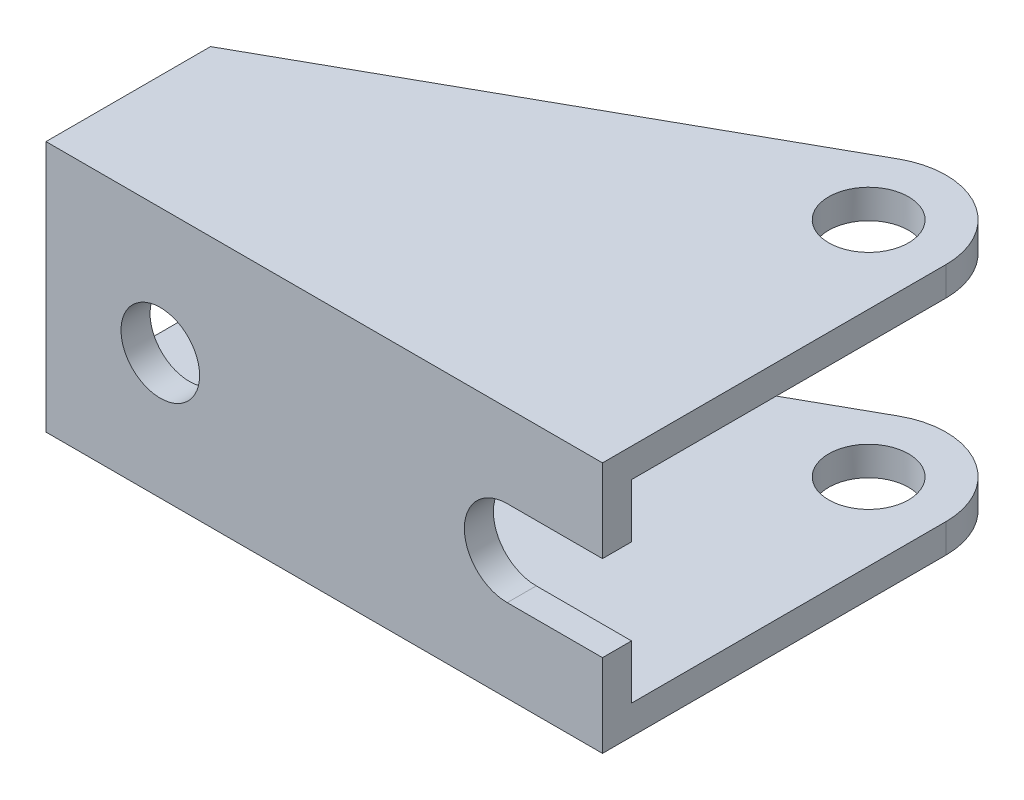
from build123d import *

# Parameters (mm, degrees)
SKETCH1_R           = 8.128
SKETCH1_R_2         = 4.191
BOSS_EXTRUDE1_DEPTH = 26.416
CUT_EXTRUDE1_REACH  = 60.42
SKETCH2_W           = 41.148
SKETCH2_H           = 20.32
CUT_EXTRUDE2_REACH  = 46.196
SKETCH3_R           = 4.125


with BuildPart() as part:
    # Sketch1 → Boss-Extrude1 (new body)
    with BuildSketch(Plane(origin=(0, 0, 0), x_dir=(1, 0, 0), z_dir=(0, 1, 0))):
        with BuildLine():
            Line((-58.42, 0), (0, 0))
            Line((0, 0), (0, 36.068))
            ThreePointArc((0, 36.068), (-12.241042079, 29.057488688), (-12.09332403, 43.163110242))
            Line((-12.09332403, 43.163110242), (-58.42, 17.272))
            Line((-58.42, 17.272), (-58.42, 0))
        make_face()
        with Locations((-8.128, 36.068)):
            Circle(SKETCH1_R)
        with Locations(Location((-8.128, 36.068, 0), (0, 0, 270))):  # turned: the seam where the file's is
            Circle(SKETCH1_R_2, mode=Mode.SUBTRACT)
    extrude(amount=-BOSS_EXTRUDE1_DEPTH)

    # Sketch2 → Cut-Extrude1 (cut, up to next)
    with BuildSketch(Plane(origin=(0, 0, 0), x_dir=(0, 0, -1), z_dir=(1, 0, 0)), mode=Mode.PRIVATE) as cut_extrude1_sk1:
        with Locations((23.622, -13.208)):
            Rectangle(SKETCH2_W, SKETCH2_H)
    cut_extrude1_tool1 = extrude(cut_extrude1_sk1.sketch, amount=-CUT_EXTRUDE1_REACH, mode=Mode.PRIVATE) & part.part
    add(cut_extrude1_tool1.solids().sort_by_distance((0, -13.208, -23.622))[0], mode=Mode.SUBTRACT)

    # Sketch3 → Cut-Extrude2 (cut, up to next)
    with BuildSketch(Plane.XY, mode=Mode.PRIVATE) as cut_extrude2_sk1:
        with Locations((-46.42, -13.208)):
            Circle(SKETCH3_R)
    cut_extrude2_tool1 = extrude(cut_extrude2_sk1.sketch, amount=-CUT_EXTRUDE2_REACH, mode=Mode.PRIVATE) & part.part
    add(cut_extrude2_tool1.solids().sort_by_distance((-46.42, -13.208, 0))[0], mode=Mode.SUBTRACT)
    # Sketch3 → Cut-Extrude2 (cut, up to next)
    with BuildSketch(Plane.XY, mode=Mode.PRIVATE) as cut_extrude2_sk2:
        with BuildLine():
            Line((0, -13.208), (0, -8.708))
            Line((0, -8.708), (-10, -8.708))
            ThreePointArc((-10, -8.708), (-14.5, -13.208), (-10, -17.708))
            Line((-10, -17.708), (0, -17.708))
            Line((0, -17.708), (0, -13.208))
        make_face()
    cut_extrude2_tool2 = extrude(cut_extrude2_sk2.sketch, amount=-CUT_EXTRUDE2_REACH, mode=Mode.PRIVATE) & part.part
    add(cut_extrude2_tool2.solids().sort_by_distance((-6.804413, -13.208, 0))[0], mode=Mode.SUBTRACT)


solid = part.part
